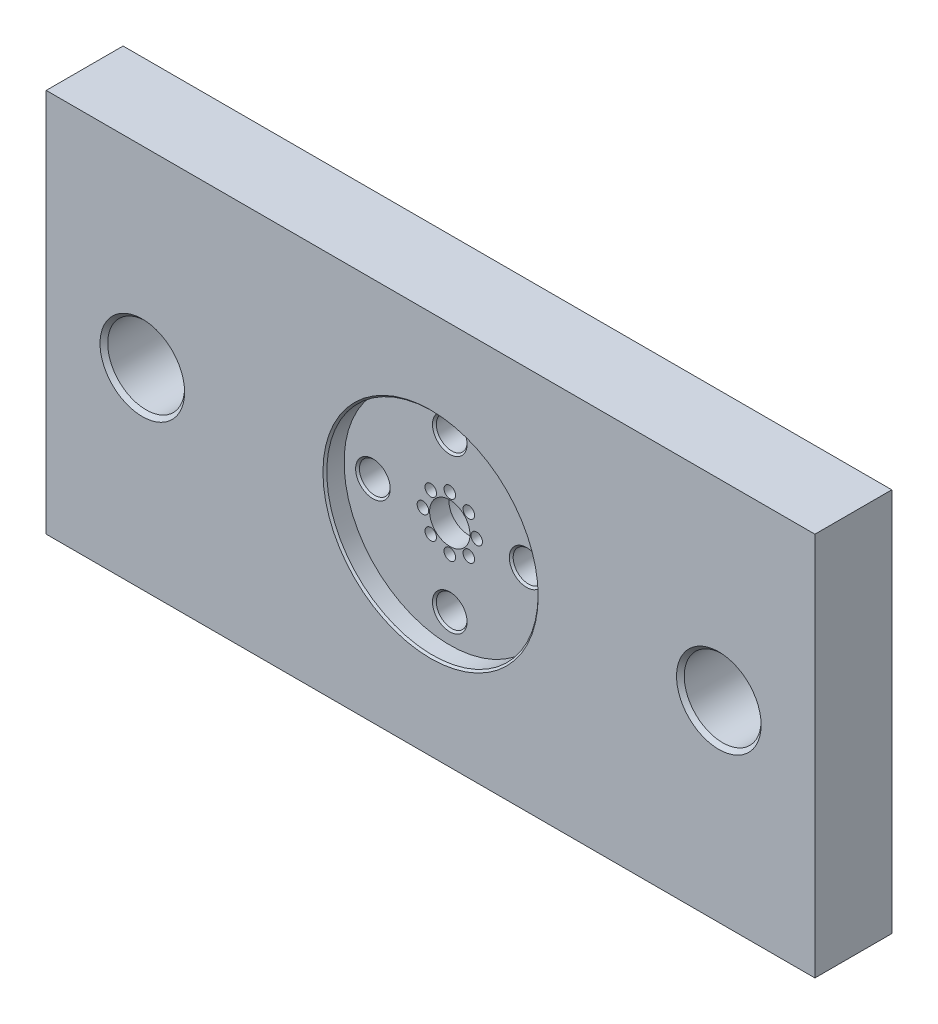
from build123d import *

# Parameters (mm, degrees)
SKETCH1_W           = 200
SKETCH1_H           = 100
BOSS_EXTRUDE1_DEPTH = 20
SKETCH2_R           = 27.5
CUT_EXTRUDE1_DEPTH  = 5
SKETCH3_R           = 4
SKETCH3_R_2         = 5.25
CUT_EXTRUDE2_DEPTH  = 16
SKETCH4_R           = 6.5
CUT_EXTRUDE3_DEPTH  = 8
CHAMFER1_SIZE       = 0.5
SKETCH5_R           = 10
CUT_EXTRUDE4_DEPTH  = 21
CHAMFER2_SIZE       = 1
SKETCH7_R           = 11
CUT_EXTRUDE5_DEPTH  = 10
CHAMFER3_SIZE       = 0.5
SKETCH8_R           = 1.5
CUT_EXTRUDE6_DEPTH  = 16


with BuildPart() as part:
    # Sketch1 → Boss-Extrude1 (new body)
    with BuildSketch(Plane.XY):
        Rectangle(SKETCH1_W, SKETCH1_H)
    extrude(amount=-BOSS_EXTRUDE1_DEPTH)

    # Sketch2 → Cut-Extrude1 (cut)
    with BuildSketch(Plane.XY):
        Circle(SKETCH2_R)
    extrude(amount=-CUT_EXTRUDE1_DEPTH, mode=Mode.SUBTRACT)

    # Sketch3 → Cut-Extrude2 (cut, through all)
    with BuildSketch(Plane.XY.offset(-5)):
        with Locations((-20, 0)):
            Circle(SKETCH3_R)
        with Locations((0, 20)):
            Circle(SKETCH3_R)
        with Locations((20, 0)):
            Circle(SKETCH3_R)
        with Locations((0, -20)):
            Circle(SKETCH3_R)
        Circle(SKETCH3_R_2)
    extrude(amount=-CUT_EXTRUDE2_DEPTH, mode=Mode.SUBTRACT)

    # Sketch4 → Cut-Extrude3 (cut)
    with BuildSketch(Plane(origin=(0, 0, -20), x_dir=(-1, 0, 0), z_dir=(0, 0, -1))):
        with Locations((0, 20)):
            Circle(SKETCH4_R)
        with Locations((20, 0)):
            Circle(SKETCH4_R)
        with Locations((0, -20)):
            Circle(SKETCH4_R)
        with Locations((-20, 0)):
            Circle(SKETCH4_R)
    extrude(amount=-CUT_EXTRUDE3_DEPTH, mode=Mode.SUBTRACT)

    # Chamfer1
    chamfer1_edges = [part.edges().sort_by_distance(p)[0] for p in [
        (-27.5, 0, 0),
        (-24, 0, -5),
        (-4, -20, -5),
        (16, 0, -5),
        (-4, 20, -5),
        (6.5, 20, -20),
        (-4, 20, -12),
        (-13.5, 0, -20),
        (-24, 0, -12),
        (6.5, -20, -20),
        (-4, -20, -12),
        (26.5, 0, -20),
        (16, 0, -12),
    ]]
    chamfer(chamfer1_edges, length=CHAMFER1_SIZE)

    # Sketch5 → Cut-Extrude4 (cut, through all)
    with BuildSketch(Plane.XY):
        with Locations((75, 0)):
            Circle(SKETCH5_R)
        with Locations((-75, 0)):
            Circle(SKETCH5_R)
    extrude(amount=-CUT_EXTRUDE4_DEPTH, mode=Mode.SUBTRACT)

    # Chamfer2
    chamfer2_edges = [part.edges().sort_by_distance(p)[0] for p in [
        (65, 0, -20),
        (65, 0, 0),
        (-85, 0, -20),
        (-85, 0, 0),
    ]]
    chamfer(chamfer2_edges, length=CHAMFER2_SIZE)

    # Sketch7 → Cut-Extrude5 (cut)
    with BuildSketch(Plane(origin=(0, 0, -20), x_dir=(-1, 0, 0), z_dir=(0, 0, -1))):
        Circle(SKETCH7_R)
    extrude(amount=-CUT_EXTRUDE5_DEPTH, mode=Mode.SUBTRACT)

    # Chamfer3
    chamfer3_edges = [part.edges().sort_by_distance(p)[0] for p in [
        (11, 0, -10),
    ]]
    chamfer(chamfer3_edges, length=CHAMFER3_SIZE)

    # Sketch8 → Cut-Extrude6 (cut, through all)
    with BuildSketch(Plane.XY.offset(-5)):
        with Locations((0, 7)):
            Circle(SKETCH8_R)
        with Locations((4.949747468, 4.949747468)):
            Circle(SKETCH8_R)
        with Locations((7, 0)):
            Circle(SKETCH8_R)
        with Locations((4.949747468, -4.949747468)):
            Circle(SKETCH8_R)
        with Locations((0, -7)):
            Circle(SKETCH8_R)
        with Locations((-4.949747468, -4.949747468)):
            Circle(SKETCH8_R)
        with Locations((-7, 0)):
            Circle(SKETCH8_R)
        with Locations((-4.949747468, 4.949747468)):
            Circle(SKETCH8_R)
    extrude(amount=-CUT_EXTRUDE6_DEPTH, mode=Mode.SUBTRACT)


solid = part.part
